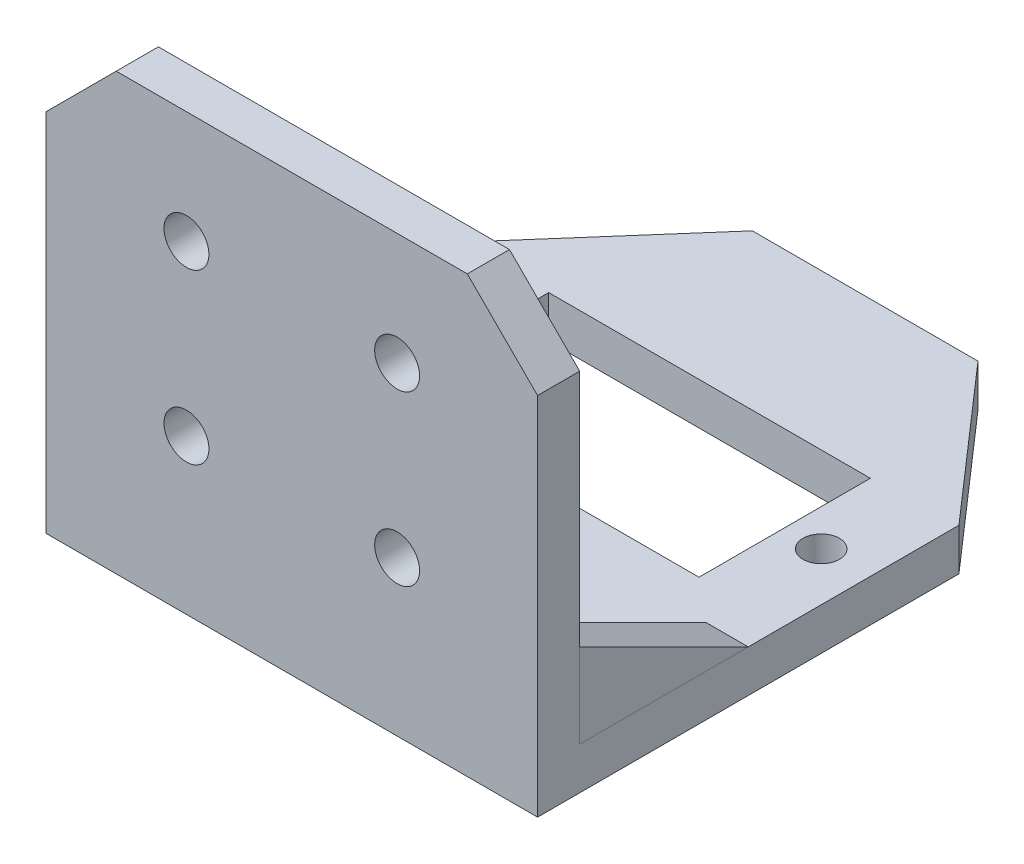
from build123d import *

# Parameters (mm, degrees)
SKETCH2_R                      = 1.3
SKETCH2_W                      = 22.9
SKETCH2_H                      = 12.2
BOSS_EXTRUDE1_DEPTH            = 3
SKETCH4_W                      = 35
SKETCH4_H                      = 3
BOSS_EXTRUDE2_DEPTH            = 28
CUT_EXTRUDE1_DEPTH             = 8
F_3_2_3_2_DIAMETER_HOLE1_D     = 3.2
F_3_2_3_2_DIAMETER_HOLE1_DEPTH = 3.2
F_3_2_3_2_DIAMETER_HOLE1_TIP   = 0.96137699
GUSSET1_THICKNESS              = 3
GUSSET2_THICKNESS              = 3


with BuildPart() as part:
    # Sketch2 → Boss-Extrude1 (new body)
    with BuildSketch(Plane(origin=(0, 0, 0), x_dir=(1, 0, 0), z_dir=(0, 1, 0))):
        Polygon((-15.281070854, -78.674622905), (-50.281070854, -78.674622905), (-50.230552623, -48.67466544), (-40.789454456, -37.874622905), (-24.722217678, -37.874622905), (-15.281070854, -48.674622905), align=None)
        with Locations(Location((-46.731070854, -55.03062717, 0), (0, 0, 270))):
            Circle(SKETCH2_R, mode=Mode.SUBTRACT)
        with Locations(Location((-18.731070854, -55.03062717, 0), (0, 0, 270))):
            Circle(SKETCH2_R, mode=Mode.SUBTRACT)
        with Locations((-32.781070854, -55.03062717)):
            Rectangle(SKETCH2_W, SKETCH2_H, mode=Mode.SUBTRACT)
    extrude(amount=BOSS_EXTRUDE1_DEPTH)

    # Sketch4 → Boss-Extrude2 (add)
    with BuildSketch(Plane(origin=(0, 3, 0), x_dir=(1, 0, 0), z_dir=(0, 1, 0))):
        with Locations((-32.781070854, -77.174622905)):
            Rectangle(SKETCH4_W, SKETCH4_H)
    extrude(amount=BOSS_EXTRUDE2_DEPTH)

    # Sketch5 → Cut-Extrude1 (cut)
    with BuildSketch(Plane(origin=(0, 0, 75.674622905), x_dir=(-1, 0, 0), z_dir=(0, 0, -1))):
        Polygon((15.281070854, 31), (15.281070854, 26), (20.281070854, 31), align=None)
        Polygon((50.281070854, 31), (45.281070854, 31), (50.281070854, 26), align=None)
    extrude(amount=-CUT_EXTRUDE1_DEPTH, mode=Mode.SUBTRACT)

    # Ø3.2 (3.2) Diameter Hole1
    with Locations(Plane(origin=(0, 0, 75.674622905), x_dir=(-1, 0, 0), z_dir=(0, 0, -1))):
        with Locations((25.281070854, 23), (40.281070854, 23), (40.281070854, 11), (25.281070854, 11), (7.430326382, 12.317521411)):
            Hole(F_3_2_3_2_DIAMETER_HOLE1_D / 2, depth=F_3_2_3_2_DIAMETER_HOLE1_DEPTH)
            with Locations((0, 0, -(F_3_2_3_2_DIAMETER_HOLE1_DEPTH + F_3_2_3_2_DIAMETER_HOLE1_TIP / 2))):  # 118° drill point
                Cone(0, F_3_2_3_2_DIAMETER_HOLE1_D / 2, F_3_2_3_2_DIAMETER_HOLE1_TIP, mode=Mode.SUBTRACT)


with BuildPart() as body_2:
    # Gusset1: a gusset: a plate 3.0 thick in the corner of two members, its outline drawn in place
    gusset1_outline = Wire([Line((-47.276019024, 3, 75.674622905), (-47.276019024, 3, 63.674622905)), Line((-47.276019024, 3, 63.674622905), (-47.276019024, 9, 75.674622905)), Line((-47.276019024, 9, 75.674622905), (-47.276019024, 3, 75.674622905))])
    add(extrude(Face(gusset1_outline), amount=GUSSET1_THICKNESS, dir=(-1, 0, 0)))


with BuildPart() as body_3:
    # Gusset2: a gusset: a plate 3.0 thick in the corner of two members, its outline drawn in place
    gusset2_outline = Wire([Line((-18.281070854, 3, 75.674622905), (-18.281070854, 9, 75.674622905)), Line((-18.281070854, 9, 75.674622905), (-18.281070854, 3, 63.674622905)), Line((-18.281070854, 3, 63.674622905), (-18.281070854, 3, 75.674622905))])
    add(extrude(Face(gusset2_outline), amount=GUSSET2_THICKNESS, dir=(1, 0, 0)))


solid = Compound([part.part, body_2.part, body_3.part])
